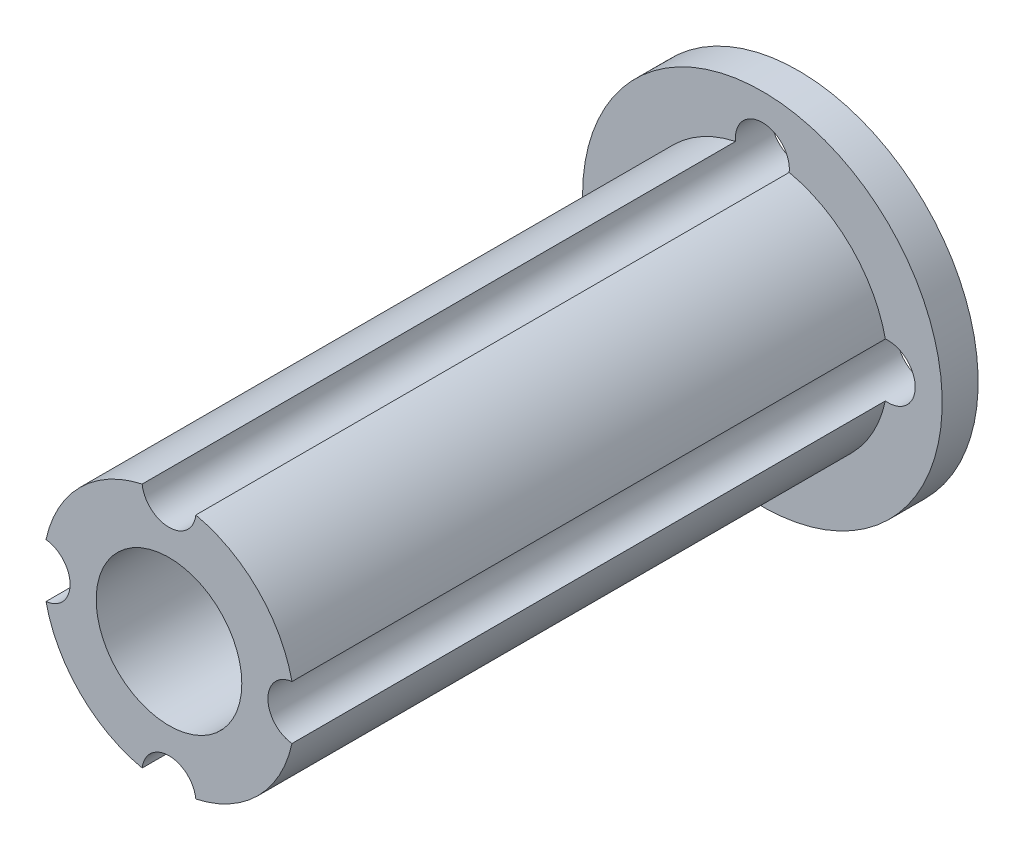
from build123d import *

# Parameters (mm, degrees)
SKETCH1_R           = 7
BOSS_EXTRUDE5_DEPTH = 35
SKETCH2_R           = 10
BOSS_EXTRUDE7_DEPTH = 2
SKETCH1_19_R        = 4.05
SKETCH1_19_R_2      = 1.5
CUT_EXTRUDE2_DEPTH  = 41


with BuildPart() as part:
    # Sketch1 → Boss-Extrude5 (new body)
    with BuildSketch(Plane.XY):
        Circle(SKETCH1_R)
    extrude(amount=BOSS_EXTRUDE5_DEPTH)

    # Sketch2 → Boss-Extrude7 (add)
    with BuildSketch(Plane(origin=(0, 0, 0), x_dir=(-1, 0, 0), z_dir=(0, 0, -1))):
        Circle(SKETCH2_R)
    extrude(amount=-BOSS_EXTRUDE7_DEPTH)

    # Sketch1_19 → Cut-Extrude2 (cut)
    with BuildSketch(Plane.XY):
        Circle(SKETCH1_19_R)
        with Locations((7, 0)):
            Circle(SKETCH1_19_R_2)
        with Locations((0, 7)):
            Circle(SKETCH1_19_R_2)
        with Locations((0, -7)):
            Circle(SKETCH1_19_R_2)
        with Locations((-7, 0)):
            Circle(SKETCH1_19_R_2)
    extrude(amount=CUT_EXTRUDE2_DEPTH, mode=Mode.SUBTRACT)


solid = part.part
